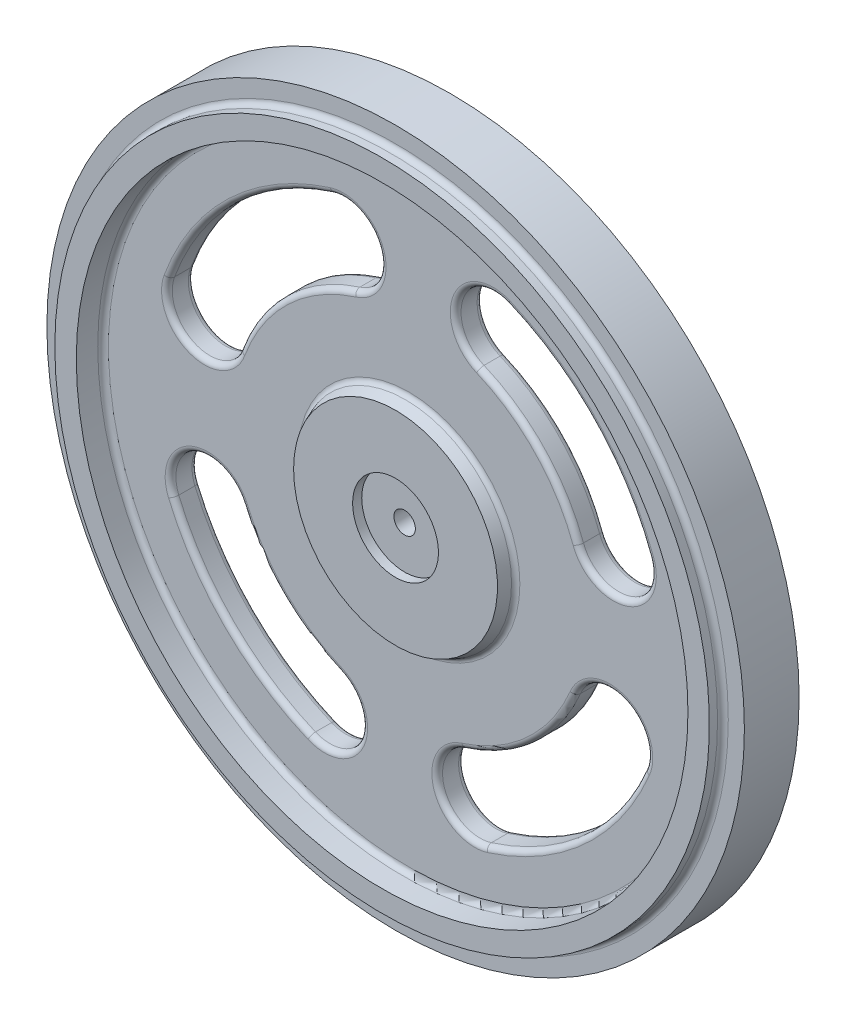
from build123d import *

# Parameters (mm, degrees)
EXTRUDE1_REACH = 7
FILLET1_R      = 0.5
EXTRUDE2_DEPTH = 3.85


with BuildPart() as part:
    # Sketch1 → Revolve1 (revolve)
    with BuildSketch(Plane(origin=(0, 0, 0), x_dir=(0, 0, -1), z_dir=(1, 0, 0)), mode=Mode.PRIVATE) as revolve1_sk:
        Polygon((-2.55, 32.5), (-2.55, 30.5), (-3.81, 30.5), (-3.81, 28.5), (-1.31, 28.5), (-1.31, 10), (-2.56, 9.5), (-2.56, 4), (-1.71, 4), (-1.71, 1), (-0.16, 1), (-0.16, 2.75), (3.69, 2.75), (3.69, 4.5), (1.19, 5), (1.19, 28.5), (3.69, 28.5), (3.69, 30.5), (2.55, 30.5), (2.55, 32.5), align=None)
    revolve(revolve1_sk.sketch.rotate(Axis((0, 0, -25), (0, 0, 1)), 90), axis=Axis((0, 0, -25), (0, 0, 1)))  # turned: the seam where the file's is

    # Sketch2 → Extrude1 (cut, up to next)
    with BuildSketch(Plane.XY.offset(1.31), mode=Mode.PRIVATE) as extrude1_sk1:
        with BuildLine():
            ThreePointArc((-5.074263955, 16.01536279), (-11.607764774, 12.144949442), (-15.769589482, 5.793103448))
            ThreePointArc((-15.769589482, 5.793103448), (-20.261817176, 3.714668858), (-22.340251766, 8.206896552))
            ThreePointArc((-22.340251766, 8.206896552), (-16.44433343, 17.205345043), (-7.188540604, 22.68843062))
            ThreePointArc((-7.188540604, 22.68843062), (-2.794868365, 20.409035029), (-5.074263955, 16.01536279))
        make_face()
    extrude1_tool1 = extrude(extrude1_sk1.sketch, amount=-EXTRUDE1_REACH, mode=Mode.PRIVATE) & part.part
    add(extrude1_tool1.solids().sort_by_distance((-13.327111, 13.943863, 1.31))[0], mode=Mode.SUBTRACT)
    # Sketch2 → Extrude1 (cut, up to next)
    with BuildSketch(Plane.XY.offset(1.31), mode=Mode.PRIVATE) as extrude1_sk2:
        with BuildLine():
            ThreePointArc((15.769589482, 5.793103448), (12.144949442, 11.607764774), (6.50009699, 15.491569937))
            ThreePointArc((6.50009699, 15.491569937), (4.626873459, 20.073167214), (9.208470736, 21.946390744))
            ThreePointArc((9.208470736, 21.946390744), (17.205345043, 16.44433343), (22.340251766, 8.206896552))
            ThreePointArc((22.340251766, 8.206896552), (20.261817176, 3.714668858), (15.769589482, 5.793103448))
        make_face()
    extrude1_tool2 = extrude(extrude1_sk2.sketch, amount=-EXTRUDE1_REACH, mode=Mode.PRIVATE) & part.part
    add(extrude1_tool2.solids().sort_by_distance((14.064816, 13.442714, 1.31))[0], mode=Mode.SUBTRACT)
    # Sketch2 → Extrude1 (cut, up to next)
    with BuildSketch(Plane.XY.offset(1.31), mode=Mode.PRIVATE) as extrude1_sk3:
        with BuildLine():
            ThreePointArc((5.074263955, -16.01536279), (11.330200869, -12.404295557), (15.491569937, -6.50009699))
            ThreePointArc((15.491569937, -6.50009699), (20.073167214, -4.626873459), (21.946390744, -9.208470736))
            ThreePointArc((21.946390744, -9.208470736), (16.051117898, -17.572752039), (7.188540604, -22.68843062))
            ThreePointArc((7.188540604, -22.68843062), (2.794868365, -20.409035029), (5.074263955, -16.01536279))
        make_face()
    extrude1_tool3 = extrude(extrude1_sk3.sketch, amount=-EXTRUDE1_REACH, mode=Mode.PRIVATE) & part.part
    add(extrude1_tool3.solids().sort_by_distance((13.06595, -14.304593, 1.31))[0], mode=Mode.SUBTRACT)
    # Sketch2 → Extrude1 (cut, up to next)
    with BuildSketch(Plane.XY.offset(1.31), mode=Mode.PRIVATE) as extrude1_sk4:
        with BuildLine():
            ThreePointArc((-15.491569937, -6.50009699), (-11.879393924, -11.879393924), (-6.50009699, -15.491569937))
            ThreePointArc((-6.50009699, -15.491569937), (-4.626873459, -20.073167214), (-9.208470736, -21.946390744))
            ThreePointArc((-9.208470736, -21.946390744), (-16.829141392, -16.829141392), (-21.946390744, -9.208470736))
            ThreePointArc((-21.946390744, -9.208470736), (-20.073167214, -4.626873459), (-15.491569937, -6.50009699))
        make_face()
    extrude1_tool4 = extrude(extrude1_sk4.sketch, amount=-EXTRUDE1_REACH, mode=Mode.PRIVATE) & part.part
    add(extrude1_tool4.solids().sort_by_distance((-13.812959, -13.812959, 1.31))[0], mode=Mode.SUBTRACT)

    # Fillet1
    fillet1_edges = [part.edges().sort_by_distance(p)[0] for p in [
        (10, 0, 1.31),
        (5, 0, -1.19),
        (28.5, 0, -1.19),
        (28.5, 0, -3.69),
        (30.5, 0, 2.55),
        (28.5, 0, 1.31),
        (-20.073167214, -4.626873459, -1.19),
        (-11.879393924, -11.879393924, -1.19),
        (-4.626873459, -20.073167214, -1.19),
        (-16.829141392, -16.829141392, -1.19),
        (-20.073167214, -4.626873459, 1.31),
        (-16.829141392, -16.829141392, 1.31),
        (-4.626873459, -20.073167214, 1.31),
        (-11.879393924, -11.879393924, 1.31),
        (2.794868365, -20.409035029, -1.19),
        (11.330200869, -12.404295557, -1.19),
        (20.073167214, -4.626873459, -1.19),
        (16.051117898, -17.572752039, -1.19),
        (2.794868365, -20.409035029, 1.31),
        (16.051117898, -17.572752039, 1.31),
        (20.073167214, -4.626873459, 1.31),
        (11.330200869, -12.404295557, 1.31),
        (-20.261817176, 3.714668858, -1.19),
        (-16.44433343, 17.205345043, -1.19),
        (-2.794868365, 20.409035029, -1.19),
        (-11.607764774, 12.144949442, -1.19),
        (-20.261817176, 3.714668858, 1.31),
        (-11.607764774, 12.144949442, 1.31),
        (-2.794868365, 20.409035029, 1.31),
        (-16.44433343, 17.205345043, 1.31),
        (20.261817176, 3.714668858, -1.19),
        (12.144949442, 11.607764774, -1.19),
        (4.626873459, 20.073167214, -1.19),
        (17.205345043, 16.44433343, -1.19),
        (20.261817176, 3.714668858, 1.31),
        (17.205345043, 16.44433343, 1.31),
        (4.626873459, 20.073167214, 1.31),
        (12.144949442, 11.607764774, 1.31),
    ]]
    fillet(fillet1_edges, radius=FILLET1_R)

    # Sketch3 → Extrude2 (cut)
    with BuildSketch(Plane(origin=(0, 0, -3.69), x_dir=(-1, 0, 0), z_dir=(0, 0, -1))):
        with BuildLine():
            Line((0.123745264, 2.76888782), (0.159844513, 2.973616835))
            ThreePointArc((0.159844513, 2.973616835), (0.168996766, 2.988915967), (0.186014831, 2.994227527))
            ThreePointArc((0.186014831, 2.994227527), (0.261467228, 2.988584094), (0.336753306, 2.981039619))
            ThreePointArc((0.336753306, 2.981039619), (0.352590485, 2.972853598), (0.358947029, 2.956197622))
            Line((0.358947029, 2.956197622), (0.358947029, 2.748310332))
            ThreePointArc((0.358947029, 2.748310332), (0.36508603, 2.731901105), (0.380488046, 2.723550779))
            ThreePointArc((0.380488046, 2.723550779), (0.429078731, 2.716319466), (0.477532489, 2.708221321))
            ThreePointArc((0.477532489, 2.708221321), (0.525833856, 2.699258927), (0.573967418, 2.689435146))
            ThreePointArc((0.573967418, 2.689435146), (0.591296559, 2.692014085), (0.60267762, 2.705334052))
            Line((0.60267762, 2.705334052), (0.67377926, 2.900684205))
            ThreePointArc((0.67377926, 2.900684205), (0.685449137, 2.914161637), (0.703131001, 2.916437346))
            ThreePointArc((0.703131001, 2.916437346), (0.776457135, 2.897777479), (0.849289364, 2.877274331))
            ThreePointArc((0.849289364, 2.877274331), (0.863464453, 2.866462577), (0.866832147, 2.84895584))
            Line((0.866832147, 2.84895584), (0.830732897, 2.644226825))
            ThreePointArc((0.830732897, 2.644226825), (0.833929201, 2.627000865), (0.847647208, 2.616102867))
            ThreePointArc((0.847647208, 2.616102867), (0.894243987, 2.60054373), (0.940555394, 2.584154707))
            ThreePointArc((0.940555394, 2.584154707), (0.986566652, 2.566941028), (1.032263076, 2.548908186))
            ThreePointArc((1.032263076, 2.548908186), (1.049776776, 2.548438772), (1.06329792, 2.559580079))
            Line((1.06329792, 2.559580079), (1.167241566, 2.739615754))
            ThreePointArc((1.167241566, 2.739615754), (1.181074482, 2.75086198), (1.198882892, 2.750032693))
            ThreePointArc((1.198882892, 2.750032693), (1.267854785, 2.718923361), (1.336020195, 2.686084518))
            ThreePointArc((1.336020195, 2.686084518), (1.348102491, 2.672975541), (1.348379009, 2.655149977))
            Line((1.348379009, 2.655149977), (1.277277368, 2.459799824))
            ThreePointArc((1.277277368, 2.459799824), (1.277433856, 2.442280533), (1.289051037, 2.429165993))
            ThreePointArc((1.289051037, 2.429165993), (1.332238091, 2.405751789), (1.375, 2.38156986))
            ThreePointArc((1.375, 2.38156986), (1.417323119, 2.356627925), (1.459193942, 2.330933942))
            ThreePointArc((1.459193942, 2.330933942), (1.476360057, 2.327430437), (1.491610452, 2.33605456))
            Line((1.491610452, 2.33605456), (1.625237827, 2.495305464))
            ThreePointArc((1.625237827, 2.495305464), (1.640813476, 2.503978774), (1.658207332, 2.500069688))
            ThreePointArc((1.658207332, 2.500069688), (1.720729309, 2.457456133), (1.782156728, 2.413279387))
            ThreePointArc((1.782156728, 2.413279387), (1.791779116, 2.398271495), (1.788956057, 2.380668725))
            Line((1.788956057, 2.380668725), (1.685012411, 2.20063305))
            ThreePointArc((1.685012411, 2.20063305), (1.682124329, 2.183352743), (1.691287704, 2.16842014))
            ThreePointArc((1.691287704, 2.16842014), (1.729752815, 2.137862297), (1.767665927, 2.106622219))
            ThreePointArc((1.767665927, 2.106622219), (1.805014941, 2.074709875), (1.841787938, 2.042135449))
            ThreePointArc((1.841787938, 2.042135449), (1.858084884, 2.035704305), (1.874601155, 2.041549205))
            Line((1.874601155, 2.041549205), (2.033852059, 2.17517658))
            ThreePointArc((2.033852059, 2.17517658), (2.050697184, 2.18101344), (2.067147982, 2.17414333))
            ThreePointArc((2.067147982, 2.17414333), (2.121320344, 2.121320344), (2.17414333, 2.067147982))
            ThreePointArc((2.17414333, 2.067147982), (2.18101344, 2.050697184), (2.17517658, 2.033852059))
            Line((2.17517658, 2.033852059), (2.041549205, 1.874601155))
            ThreePointArc((2.041549205, 1.874601155), (2.035704305, 1.858084884), (2.042135449, 1.841787938))
            ThreePointArc((2.042135449, 1.841787938), (2.074709875, 1.805014941), (2.106622219, 1.767665927))
            ThreePointArc((2.106622219, 1.767665927), (2.137862297, 1.729752815), (2.16842014, 1.691287704))
            ThreePointArc((2.16842014, 1.691287704), (2.183352743, 1.682124329), (2.20063305, 1.685012411))
            Line((2.20063305, 1.685012411), (2.380668725, 1.788956057))
            ThreePointArc((2.380668725, 1.788956057), (2.398271495, 1.791779116), (2.413279387, 1.782156728))
            ThreePointArc((2.413279387, 1.782156728), (2.457456133, 1.720729309), (2.500069688, 1.658207332))
            ThreePointArc((2.500069688, 1.658207332), (2.503978774, 1.640813476), (2.495305464, 1.625237827))
            Line((2.495305464, 1.625237827), (2.33605456, 1.491610452))
            ThreePointArc((2.33605456, 1.491610452), (2.327430437, 1.476360057), (2.330933942, 1.459193942))
            ThreePointArc((2.330933942, 1.459193942), (2.356627925, 1.417323119), (2.38156986, 1.375))
            ThreePointArc((2.38156986, 1.375), (2.405751789, 1.332238091), (2.429165993, 1.289051037))
            ThreePointArc((2.429165993, 1.289051037), (2.442280533, 1.277433856), (2.459799824, 1.277277368))
            Line((2.459799824, 1.277277368), (2.655149977, 1.348379009))
            ThreePointArc((2.655149977, 1.348379009), (2.672975541, 1.348102491), (2.686084518, 1.336020195))
            ThreePointArc((2.686084518, 1.336020195), (2.718923361, 1.267854785), (2.750032693, 1.198882892))
            ThreePointArc((2.750032693, 1.198882892), (2.75086198, 1.181074482), (2.739615754, 1.167241566))
            Line((2.739615754, 1.167241566), (2.559580079, 1.06329792))
            ThreePointArc((2.559580079, 1.06329792), (2.548438772, 1.049776776), (2.548908186, 1.032263076))
            ThreePointArc((2.548908186, 1.032263076), (2.566941028, 0.986566652), (2.584154707, 0.940555394))
            ThreePointArc((2.584154707, 0.940555394), (2.60054373, 0.894243987), (2.616102867, 0.847647208))
            ThreePointArc((2.616102867, 0.847647208), (2.627000865, 0.833929201), (2.644226825, 0.830732897))
            Line((2.644226825, 0.830732897), (2.84895584, 0.866832147))
            ThreePointArc((2.84895584, 0.866832147), (2.866462577, 0.863464453), (2.877274331, 0.849289364))
            ThreePointArc((2.877274331, 0.849289364), (2.897777479, 0.776457135), (2.916437346, 0.703131001))
            ThreePointArc((2.916437346, 0.703131001), (2.914161637, 0.685449137), (2.900684205, 0.67377926))
            Line((2.900684205, 0.67377926), (2.705334052, 0.60267762))
            ThreePointArc((2.705334052, 0.60267762), (2.692014085, 0.591296559), (2.689435146, 0.573967418))
            ThreePointArc((2.689435146, 0.573967418), (2.699258927, 0.525833856), (2.708221321, 0.477532489))
            ThreePointArc((2.708221321, 0.477532489), (2.716319466, 0.429078731), (2.723550779, 0.380488046))
            ThreePointArc((2.723550779, 0.380488046), (2.731901105, 0.36508603), (2.748310332, 0.358947029))
            Line((2.748310332, 0.358947029), (2.956197622, 0.358947029))
            ThreePointArc((2.956197622, 0.358947029), (2.972853598, 0.352590485), (2.981039619, 0.336753306))
            ThreePointArc((2.981039619, 0.336753306), (2.988584094, 0.261467228), (2.994227527, 0.186014831))
            ThreePointArc((2.994227527, 0.186014831), (2.988915967, 0.168996766), (2.973616835, 0.159844513))
            Line((2.973616835, 0.159844513), (2.76888782, 0.123745264))
            ThreePointArc((2.76888782, 0.123745264), (2.753793912, 0.114850096), (2.748244979, 0.098232052))
            ThreePointArc((2.748244979, 0.098232052), (2.74956121, 0.049123864), (2.75, 0))
            ThreePointArc((2.75, 0), (2.74956121, -0.049123864), (2.748244979, -0.098232052))
            ThreePointArc((2.748244979, -0.098232052), (2.753793912, -0.114850096), (2.76888782, -0.123745264))
            Line((2.76888782, -0.123745264), (2.973616835, -0.159844513))
            ThreePointArc((2.973616835, -0.159844513), (2.988915967, -0.168996766), (2.994227527, -0.186014831))
            ThreePointArc((2.994227527, -0.186014831), (2.988584094, -0.261467228), (2.981039619, -0.336753306))
            ThreePointArc((2.981039619, -0.336753306), (2.972853598, -0.352590485), (2.956197622, -0.358947029))
            Line((2.956197622, -0.358947029), (2.748310332, -0.358947029))
            ThreePointArc((2.748310332, -0.358947029), (2.731901105, -0.36508603), (2.723550779, -0.380488046))
            ThreePointArc((2.723550779, -0.380488046), (2.716319466, -0.429078731), (2.708221321, -0.477532489))
            ThreePointArc((2.708221321, -0.477532489), (2.699258927, -0.525833856), (2.689435146, -0.573967418))
            ThreePointArc((2.689435146, -0.573967418), (2.692014085, -0.591296559), (2.705334052, -0.60267762))
            Line((2.705334052, -0.60267762), (2.900684205, -0.67377926))
            ThreePointArc((2.900684205, -0.67377926), (2.914161637, -0.685449137), (2.916437346, -0.703131001))
            ThreePointArc((2.916437346, -0.703131001), (2.897777479, -0.776457135), (2.877274331, -0.849289364))
            ThreePointArc((2.877274331, -0.849289364), (2.866462577, -0.863464453), (2.84895584, -0.866832147))
            Line((2.84895584, -0.866832147), (2.644226825, -0.830732897))
            ThreePointArc((2.644226825, -0.830732897), (2.627000865, -0.833929201), (2.616102867, -0.847647208))
            ThreePointArc((2.616102867, -0.847647208), (2.60054373, -0.894243987), (2.584154707, -0.940555394))
            ThreePointArc((2.584154707, -0.940555394), (2.566941028, -0.986566652), (2.548908186, -1.032263076))
            ThreePointArc((2.548908186, -1.032263076), (2.548438772, -1.049776776), (2.559580079, -1.06329792))
            Line((2.559580079, -1.06329792), (2.739615754, -1.167241566))
            ThreePointArc((2.739615754, -1.167241566), (2.75086198, -1.181074482), (2.750032693, -1.198882892))
            ThreePointArc((2.750032693, -1.198882892), (2.718923361, -1.267854785), (2.686084518, -1.336020195))
            ThreePointArc((2.686084518, -1.336020195), (2.672975541, -1.348102491), (2.655149977, -1.348379009))
            Line((2.655149977, -1.348379009), (2.459799824, -1.277277368))
            ThreePointArc((2.459799824, -1.277277368), (2.442280533, -1.277433856), (2.429165993, -1.289051037))
            ThreePointArc((2.429165993, -1.289051037), (2.405751789, -1.332238091), (2.38156986, -1.375))
            ThreePointArc((2.38156986, -1.375), (2.356627925, -1.417323119), (2.330933942, -1.459193942))
            ThreePointArc((2.330933942, -1.459193942), (2.327430437, -1.476360057), (2.33605456, -1.491610452))
            Line((2.33605456, -1.491610452), (2.495305464, -1.625237827))
            ThreePointArc((2.495305464, -1.625237827), (2.503978774, -1.640813476), (2.500069688, -1.658207332))
            ThreePointArc((2.500069688, -1.658207332), (2.457456133, -1.720729309), (2.413279387, -1.782156728))
            ThreePointArc((2.413279387, -1.782156728), (2.398271495, -1.791779116), (2.380668725, -1.788956057))
            Line((2.380668725, -1.788956057), (2.20063305, -1.685012411))
            ThreePointArc((2.20063305, -1.685012411), (2.183352743, -1.682124329), (2.16842014, -1.691287704))
            ThreePointArc((2.16842014, -1.691287704), (2.137862297, -1.729752815), (2.106622219, -1.767665927))
            ThreePointArc((2.106622219, -1.767665927), (2.074709875, -1.805014941), (2.042135449, -1.841787938))
            ThreePointArc((2.042135449, -1.841787938), (2.035704305, -1.858084884), (2.041549205, -1.874601155))
            Line((2.041549205, -1.874601155), (2.17517658, -2.033852059))
            ThreePointArc((2.17517658, -2.033852059), (2.18101344, -2.050697184), (2.17414333, -2.067147982))
            ThreePointArc((2.17414333, -2.067147982), (2.121320344, -2.121320344), (2.067147982, -2.17414333))
            ThreePointArc((2.067147982, -2.17414333), (2.050697184, -2.18101344), (2.033852059, -2.17517658))
            Line((2.033852059, -2.17517658), (1.874601155, -2.041549205))
            ThreePointArc((1.874601155, -2.041549205), (1.858084884, -2.035704305), (1.841787938, -2.042135449))
            ThreePointArc((1.841787938, -2.042135449), (1.805014941, -2.074709875), (1.767665927, -2.106622219))
            ThreePointArc((1.767665927, -2.106622219), (1.729752815, -2.137862297), (1.691287704, -2.16842014))
            ThreePointArc((1.691287704, -2.16842014), (1.682124329, -2.183352743), (1.685012411, -2.20063305))
            Line((1.685012411, -2.20063305), (1.788956057, -2.380668725))
            ThreePointArc((1.788956057, -2.380668725), (1.791779116, -2.398271495), (1.782156728, -2.413279387))
            ThreePointArc((1.782156728, -2.413279387), (1.720729309, -2.457456133), (1.658207332, -2.500069688))
            ThreePointArc((1.658207332, -2.500069688), (1.640813476, -2.503978774), (1.625237827, -2.495305464))
            Line((1.625237827, -2.495305464), (1.491610452, -2.33605456))
            ThreePointArc((1.491610452, -2.33605456), (1.476360057, -2.327430437), (1.459193942, -2.330933942))
            ThreePointArc((1.459193942, -2.330933942), (1.417323119, -2.356627925), (1.375, -2.38156986))
            ThreePointArc((1.375, -2.38156986), (1.332238091, -2.405751789), (1.289051037, -2.429165993))
            ThreePointArc((1.289051037, -2.429165993), (1.277433856, -2.442280533), (1.277277368, -2.459799824))
            Line((1.277277368, -2.459799824), (1.348379009, -2.655149977))
            ThreePointArc((1.348379009, -2.655149977), (1.348102491, -2.672975541), (1.336020195, -2.686084518))
            ThreePointArc((1.336020195, -2.686084518), (1.267854785, -2.718923361), (1.198882892, -2.750032693))
            ThreePointArc((1.198882892, -2.750032693), (1.181074482, -2.75086198), (1.167241566, -2.739615754))
            Line((1.167241566, -2.739615754), (1.06329792, -2.559580079))
            ThreePointArc((1.06329792, -2.559580079), (1.049776776, -2.548438772), (1.032263076, -2.548908186))
            ThreePointArc((1.032263076, -2.548908186), (0.986566652, -2.566941028), (0.940555394, -2.584154707))
            ThreePointArc((0.940555394, -2.584154707), (0.894243987, -2.60054373), (0.847647208, -2.616102867))
            ThreePointArc((0.847647208, -2.616102867), (0.833929201, -2.627000865), (0.830732897, -2.644226825))
            Line((0.830732897, -2.644226825), (0.866832147, -2.84895584))
            ThreePointArc((0.866832147, -2.84895584), (0.863464453, -2.866462577), (0.849289364, -2.877274331))
            ThreePointArc((0.849289364, -2.877274331), (0.776457135, -2.897777479), (0.703131001, -2.916437346))
            ThreePointArc((0.703131001, -2.916437346), (0.685449137, -2.914161637), (0.67377926, -2.900684205))
            Line((0.67377926, -2.900684205), (0.60267762, -2.705334052))
            ThreePointArc((0.60267762, -2.705334052), (0.591296559, -2.692014085), (0.573967418, -2.689435146))
            ThreePointArc((0.573967418, -2.689435146), (0.525833856, -2.699258927), (0.477532489, -2.708221321))
            ThreePointArc((0.477532489, -2.708221321), (0.429078731, -2.716319466), (0.380488046, -2.723550779))
            ThreePointArc((0.380488046, -2.723550779), (0.36508603, -2.731901105), (0.358947029, -2.748310332))
            Line((0.358947029, -2.748310332), (0.358947029, -2.956197622))
            ThreePointArc((0.358947029, -2.956197622), (0.352590485, -2.972853598), (0.336753306, -2.981039619))
            ThreePointArc((0.336753306, -2.981039619), (0.261467228, -2.988584094), (0.186014831, -2.994227527))
            ThreePointArc((0.186014831, -2.994227527), (0.168996766, -2.988915967), (0.159844513, -2.973616835))
            Line((0.159844513, -2.973616835), (0.123745264, -2.76888782))
            ThreePointArc((0.123745264, -2.76888782), (0.114850096, -2.753793912), (0.098232052, -2.748244979))
            ThreePointArc((0.098232052, -2.748244979), (0.049123864, -2.74956121), (0, -2.75))
            ThreePointArc((0, -2.75), (-0.049123864, -2.74956121), (-0.098232052, -2.748244979))
            ThreePointArc((-0.098232052, -2.748244979), (-0.114850096, -2.753793912), (-0.123745264, -2.76888782))
            Line((-0.123745264, -2.76888782), (-0.159844513, -2.973616835))
            ThreePointArc((-0.159844513, -2.973616835), (-0.168996766, -2.988915967), (-0.186014831, -2.994227527))
            ThreePointArc((-0.186014831, -2.994227527), (-0.261467228, -2.988584094), (-0.336753306, -2.981039619))
            ThreePointArc((-0.336753306, -2.981039619), (-0.352590485, -2.972853598), (-0.358947029, -2.956197622))
            Line((-0.358947029, -2.956197622), (-0.358947029, -2.748310332))
            ThreePointArc((-0.358947029, -2.748310332), (-0.36508603, -2.731901105), (-0.380488046, -2.723550779))
            ThreePointArc((-0.380488046, -2.723550779), (-0.429078731, -2.716319466), (-0.477532489, -2.708221321))
            ThreePointArc((-0.477532489, -2.708221321), (-0.525833856, -2.699258927), (-0.573967418, -2.689435146))
            ThreePointArc((-0.573967418, -2.689435146), (-0.591296559, -2.692014085), (-0.60267762, -2.705334052))
            Line((-0.60267762, -2.705334052), (-0.67377926, -2.900684205))
            ThreePointArc((-0.67377926, -2.900684205), (-0.685449137, -2.914161637), (-0.703131001, -2.916437346))
            ThreePointArc((-0.703131001, -2.916437346), (-0.776457135, -2.897777479), (-0.849289364, -2.877274331))
            ThreePointArc((-0.849289364, -2.877274331), (-0.863464453, -2.866462577), (-0.866832147, -2.84895584))
            Line((-0.866832147, -2.84895584), (-0.830732897, -2.644226825))
            ThreePointArc((-0.830732897, -2.644226825), (-0.833929201, -2.627000865), (-0.847647208, -2.616102867))
            ThreePointArc((-0.847647208, -2.616102867), (-0.894243987, -2.60054373), (-0.940555394, -2.584154707))
            ThreePointArc((-0.940555394, -2.584154707), (-0.986566652, -2.566941028), (-1.032263076, -2.548908186))
            ThreePointArc((-1.032263076, -2.548908186), (-1.049776776, -2.548438772), (-1.06329792, -2.559580079))
            Line((-1.06329792, -2.559580079), (-1.167241566, -2.739615754))
            ThreePointArc((-1.167241566, -2.739615754), (-1.181074482, -2.75086198), (-1.198882892, -2.750032693))
            ThreePointArc((-1.198882892, -2.750032693), (-1.267854785, -2.718923361), (-1.336020195, -2.686084518))
            ThreePointArc((-1.336020195, -2.686084518), (-1.348102491, -2.672975541), (-1.348379009, -2.655149977))
            Line((-1.348379009, -2.655149977), (-1.277277368, -2.459799824))
            ThreePointArc((-1.277277368, -2.459799824), (-1.277433856, -2.442280533), (-1.289051037, -2.429165993))
            ThreePointArc((-1.289051037, -2.429165993), (-1.332238091, -2.405751789), (-1.375, -2.38156986))
            ThreePointArc((-1.375, -2.38156986), (-1.417323119, -2.356627925), (-1.459193942, -2.330933942))
            ThreePointArc((-1.459193942, -2.330933942), (-1.476360057, -2.327430437), (-1.491610452, -2.33605456))
            Line((-1.491610452, -2.33605456), (-1.625237827, -2.495305464))
            ThreePointArc((-1.625237827, -2.495305464), (-1.640813476, -2.503978774), (-1.658207332, -2.500069688))
            ThreePointArc((-1.658207332, -2.500069688), (-1.720729309, -2.457456133), (-1.782156728, -2.413279387))
            ThreePointArc((-1.782156728, -2.413279387), (-1.791779116, -2.398271495), (-1.788956057, -2.380668725))
            Line((-1.788956057, -2.380668725), (-1.685012411, -2.20063305))
            ThreePointArc((-1.685012411, -2.20063305), (-1.682124329, -2.183352743), (-1.691287704, -2.16842014))
            ThreePointArc((-1.691287704, -2.16842014), (-1.729752815, -2.137862297), (-1.767665927, -2.106622219))
            ThreePointArc((-1.767665927, -2.106622219), (-1.805014941, -2.074709875), (-1.841787938, -2.042135449))
            ThreePointArc((-1.841787938, -2.042135449), (-1.858084884, -2.035704305), (-1.874601155, -2.041549205))
            Line((-1.874601155, -2.041549205), (-2.033852059, -2.17517658))
            ThreePointArc((-2.033852059, -2.17517658), (-2.050697184, -2.18101344), (-2.067147982, -2.17414333))
            ThreePointArc((-2.067147982, -2.17414333), (-2.121320344, -2.121320344), (-2.17414333, -2.067147982))
            ThreePointArc((-2.17414333, -2.067147982), (-2.18101344, -2.050697184), (-2.17517658, -2.033852059))
            Line((-2.17517658, -2.033852059), (-2.041549205, -1.874601155))
            ThreePointArc((-2.041549205, -1.874601155), (-2.035704305, -1.858084884), (-2.042135449, -1.841787938))
            ThreePointArc((-2.042135449, -1.841787938), (-2.074709875, -1.805014941), (-2.106622219, -1.767665927))
            ThreePointArc((-2.106622219, -1.767665927), (-2.137862297, -1.729752815), (-2.16842014, -1.691287704))
            ThreePointArc((-2.16842014, -1.691287704), (-2.183352743, -1.682124329), (-2.20063305, -1.685012411))
            Line((-2.20063305, -1.685012411), (-2.380668725, -1.788956057))
            ThreePointArc((-2.380668725, -1.788956057), (-2.398271495, -1.791779116), (-2.413279387, -1.782156728))
            ThreePointArc((-2.413279387, -1.782156728), (-2.457456133, -1.720729309), (-2.500069688, -1.658207332))
            ThreePointArc((-2.500069688, -1.658207332), (-2.503978774, -1.640813476), (-2.495305464, -1.625237827))
            Line((-2.495305464, -1.625237827), (-2.33605456, -1.491610452))
            ThreePointArc((-2.33605456, -1.491610452), (-2.327430437, -1.476360057), (-2.330933942, -1.459193942))
            ThreePointArc((-2.330933942, -1.459193942), (-2.356627925, -1.417323119), (-2.38156986, -1.375))
            ThreePointArc((-2.38156986, -1.375), (-2.405751789, -1.332238091), (-2.429165993, -1.289051037))
            ThreePointArc((-2.429165993, -1.289051037), (-2.442280533, -1.277433856), (-2.459799824, -1.277277368))
            Line((-2.459799824, -1.277277368), (-2.655149977, -1.348379009))
            ThreePointArc((-2.655149977, -1.348379009), (-2.672975541, -1.348102491), (-2.686084518, -1.336020195))
            ThreePointArc((-2.686084518, -1.336020195), (-2.718923361, -1.267854785), (-2.750032693, -1.198882892))
            ThreePointArc((-2.750032693, -1.198882892), (-2.75086198, -1.181074482), (-2.739615754, -1.167241566))
            Line((-2.739615754, -1.167241566), (-2.559580079, -1.06329792))
            ThreePointArc((-2.559580079, -1.06329792), (-2.548438772, -1.049776776), (-2.548908186, -1.032263076))
            ThreePointArc((-2.548908186, -1.032263076), (-2.566941028, -0.986566652), (-2.584154707, -0.940555394))
            ThreePointArc((-2.584154707, -0.940555394), (-2.60054373, -0.894243987), (-2.616102867, -0.847647208))
            ThreePointArc((-2.616102867, -0.847647208), (-2.627000865, -0.833929201), (-2.644226825, -0.830732897))
            Line((-2.644226825, -0.830732897), (-2.84895584, -0.866832147))
            ThreePointArc((-2.84895584, -0.866832147), (-2.866462577, -0.863464453), (-2.877274331, -0.849289364))
            ThreePointArc((-2.877274331, -0.849289364), (-2.897777479, -0.776457135), (-2.916437346, -0.703131001))
            ThreePointArc((-2.916437346, -0.703131001), (-2.914161637, -0.685449137), (-2.900684205, -0.67377926))
            Line((-2.900684205, -0.67377926), (-2.705334052, -0.60267762))
            ThreePointArc((-2.705334052, -0.60267762), (-2.692014085, -0.591296559), (-2.689435146, -0.573967418))
            ThreePointArc((-2.689435146, -0.573967418), (-2.699258927, -0.525833856), (-2.708221321, -0.477532489))
            ThreePointArc((-2.708221321, -0.477532489), (-2.716319466, -0.429078731), (-2.723550779, -0.380488046))
            ThreePointArc((-2.723550779, -0.380488046), (-2.731901105, -0.36508603), (-2.748310332, -0.358947029))
            Line((-2.748310332, -0.358947029), (-2.956197622, -0.358947029))
            ThreePointArc((-2.956197622, -0.358947029), (-2.972853598, -0.352590485), (-2.981039619, -0.336753306))
            ThreePointArc((-2.981039619, -0.336753306), (-2.988584094, -0.261467228), (-2.994227527, -0.186014831))
            ThreePointArc((-2.994227527, -0.186014831), (-2.988915967, -0.168996766), (-2.973616835, -0.159844513))
            Line((-2.973616835, -0.159844513), (-2.76888782, -0.123745264))
            ThreePointArc((-2.76888782, -0.123745264), (-2.753793912, -0.114850096), (-2.748244979, -0.098232052))
            ThreePointArc((-2.748244979, -0.098232052), (-2.74956121, -0.049123864), (-2.75, 0))
            ThreePointArc((-2.75, 0), (-2.74956121, 0.049123864), (-2.748244979, 0.098232052))
            ThreePointArc((-2.748244979, 0.098232052), (-2.753793912, 0.114850096), (-2.76888782, 0.123745264))
            Line((-2.76888782, 0.123745264), (-2.973616835, 0.159844513))
            ThreePointArc((-2.973616835, 0.159844513), (-2.988915967, 0.168996766), (-2.994227527, 0.186014831))
            ThreePointArc((-2.994227527, 0.186014831), (-2.988584094, 0.261467228), (-2.981039619, 0.336753306))
            ThreePointArc((-2.981039619, 0.336753306), (-2.972853598, 0.352590485), (-2.956197622, 0.358947029))
            Line((-2.956197622, 0.358947029), (-2.748310332, 0.358947029))
            ThreePointArc((-2.748310332, 0.358947029), (-2.731901105, 0.36508603), (-2.723550779, 0.380488046))
            ThreePointArc((-2.723550779, 0.380488046), (-2.716319466, 0.429078731), (-2.708221321, 0.477532489))
            ThreePointArc((-2.708221321, 0.477532489), (-2.699258927, 0.525833856), (-2.689435146, 0.573967418))
            ThreePointArc((-2.689435146, 0.573967418), (-2.692014085, 0.591296559), (-2.705334052, 0.60267762))
            Line((-2.705334052, 0.60267762), (-2.900684205, 0.67377926))
            ThreePointArc((-2.900684205, 0.67377926), (-2.914161637, 0.685449137), (-2.916437346, 0.703131001))
            ThreePointArc((-2.916437346, 0.703131001), (-2.897777479, 0.776457135), (-2.877274331, 0.849289364))
            ThreePointArc((-2.877274331, 0.849289364), (-2.866462577, 0.863464453), (-2.84895584, 0.866832147))
            Line((-2.84895584, 0.866832147), (-2.644226825, 0.830732897))
            ThreePointArc((-2.644226825, 0.830732897), (-2.627000865, 0.833929201), (-2.616102867, 0.847647208))
            ThreePointArc((-2.616102867, 0.847647208), (-2.60054373, 0.894243987), (-2.584154707, 0.940555394))
            ThreePointArc((-2.584154707, 0.940555394), (-2.566941028, 0.986566652), (-2.548908186, 1.032263076))
            ThreePointArc((-2.548908186, 1.032263076), (-2.548438772, 1.049776776), (-2.559580079, 1.06329792))
            Line((-2.559580079, 1.06329792), (-2.739615754, 1.167241566))
            ThreePointArc((-2.739615754, 1.167241566), (-2.75086198, 1.181074482), (-2.750032693, 1.198882892))
            ThreePointArc((-2.750032693, 1.198882892), (-2.718923361, 1.267854785), (-2.686084518, 1.336020195))
            ThreePointArc((-2.686084518, 1.336020195), (-2.672975541, 1.348102491), (-2.655149977, 1.348379009))
            Line((-2.655149977, 1.348379009), (-2.459799824, 1.277277368))
            ThreePointArc((-2.459799824, 1.277277368), (-2.442280533, 1.277433856), (-2.429165993, 1.289051037))
            ThreePointArc((-2.429165993, 1.289051037), (-2.405751789, 1.332238091), (-2.38156986, 1.375))
            ThreePointArc((-2.38156986, 1.375), (-2.356627925, 1.417323119), (-2.330933942, 1.459193942))
            ThreePointArc((-2.330933942, 1.459193942), (-2.327430437, 1.476360057), (-2.33605456, 1.491610452))
            Line((-2.33605456, 1.491610452), (-2.495305464, 1.625237827))
            ThreePointArc((-2.495305464, 1.625237827), (-2.503978774, 1.640813476), (-2.500069688, 1.658207332))
            ThreePointArc((-2.500069688, 1.658207332), (-2.457456133, 1.720729309), (-2.413279387, 1.782156728))
            ThreePointArc((-2.413279387, 1.782156728), (-2.398271495, 1.791779116), (-2.380668725, 1.788956057))
            Line((-2.380668725, 1.788956057), (-2.20063305, 1.685012411))
            ThreePointArc((-2.20063305, 1.685012411), (-2.183352743, 1.682124329), (-2.16842014, 1.691287704))
            ThreePointArc((-2.16842014, 1.691287704), (-2.137862297, 1.729752815), (-2.106622219, 1.767665927))
            ThreePointArc((-2.106622219, 1.767665927), (-2.074709875, 1.805014941), (-2.042135449, 1.841787938))
            ThreePointArc((-2.042135449, 1.841787938), (-2.035704305, 1.858084884), (-2.041549205, 1.874601155))
            Line((-2.041549205, 1.874601155), (-2.17517658, 2.033852059))
            ThreePointArc((-2.17517658, 2.033852059), (-2.18101344, 2.050697184), (-2.17414333, 2.067147982))
            ThreePointArc((-2.17414333, 2.067147982), (-2.121320344, 2.121320344), (-2.067147982, 2.17414333))
            ThreePointArc((-2.067147982, 2.17414333), (-2.050697184, 2.18101344), (-2.033852059, 2.17517658))
            Line((-2.033852059, 2.17517658), (-1.874601155, 2.041549205))
            ThreePointArc((-1.874601155, 2.041549205), (-1.858084884, 2.035704305), (-1.841787938, 2.042135449))
            ThreePointArc((-1.841787938, 2.042135449), (-1.805014941, 2.074709875), (-1.767665927, 2.106622219))
            ThreePointArc((-1.767665927, 2.106622219), (-1.729752815, 2.137862297), (-1.691287704, 2.16842014))
            ThreePointArc((-1.691287704, 2.16842014), (-1.682124329, 2.183352743), (-1.685012411, 2.20063305))
            Line((-1.685012411, 2.20063305), (-1.788956057, 2.380668725))
            ThreePointArc((-1.788956057, 2.380668725), (-1.791779116, 2.398271495), (-1.782156728, 2.413279387))
            ThreePointArc((-1.782156728, 2.413279387), (-1.720729309, 2.457456133), (-1.658207332, 2.500069688))
            ThreePointArc((-1.658207332, 2.500069688), (-1.640813476, 2.503978774), (-1.625237827, 2.495305464))
            Line((-1.625237827, 2.495305464), (-1.491610452, 2.33605456))
            ThreePointArc((-1.491610452, 2.33605456), (-1.476360057, 2.327430437), (-1.459193942, 2.330933942))
            ThreePointArc((-1.459193942, 2.330933942), (-1.417323119, 2.356627925), (-1.375, 2.38156986))
            ThreePointArc((-1.375, 2.38156986), (-1.332238091, 2.405751789), (-1.289051037, 2.429165993))
            ThreePointArc((-1.289051037, 2.429165993), (-1.277433856, 2.442280533), (-1.277277368, 2.459799824))
            Line((-1.277277368, 2.459799824), (-1.348379009, 2.655149977))
            ThreePointArc((-1.348379009, 2.655149977), (-1.348102491, 2.672975541), (-1.336020195, 2.686084518))
            ThreePointArc((-1.336020195, 2.686084518), (-1.267854785, 2.718923361), (-1.198882892, 2.750032693))
            ThreePointArc((-1.198882892, 2.750032693), (-1.181074482, 2.75086198), (-1.167241566, 2.739615754))
            Line((-1.167241566, 2.739615754), (-1.06329792, 2.559580079))
            ThreePointArc((-1.06329792, 2.559580079), (-1.049776776, 2.548438772), (-1.032263076, 2.548908186))
            ThreePointArc((-1.032263076, 2.548908186), (-0.986566652, 2.566941028), (-0.940555394, 2.584154707))
            ThreePointArc((-0.940555394, 2.584154707), (-0.894243987, 2.60054373), (-0.847647208, 2.616102867))
            ThreePointArc((-0.847647208, 2.616102867), (-0.833929201, 2.627000865), (-0.830732897, 2.644226825))
            Line((-0.830732897, 2.644226825), (-0.866832147, 2.84895584))
            ThreePointArc((-0.866832147, 2.84895584), (-0.863464453, 2.866462577), (-0.849289364, 2.877274331))
            ThreePointArc((-0.849289364, 2.877274331), (-0.776457135, 2.897777479), (-0.703131001, 2.916437346))
            ThreePointArc((-0.703131001, 2.916437346), (-0.685449137, 2.914161637), (-0.67377926, 2.900684205))
            Line((-0.67377926, 2.900684205), (-0.60267762, 2.705334052))
            ThreePointArc((-0.60267762, 2.705334052), (-0.591296559, 2.692014085), (-0.573967418, 2.689435146))
            ThreePointArc((-0.573967418, 2.689435146), (-0.525833856, 2.699258927), (-0.477532489, 2.708221321))
            ThreePointArc((-0.477532489, 2.708221321), (-0.429078731, 2.716319466), (-0.380488046, 2.723550779))
            ThreePointArc((-0.380488046, 2.723550779), (-0.36508603, 2.731901105), (-0.358947029, 2.748310332))
            Line((-0.358947029, 2.748310332), (-0.358947029, 2.956197622))
            ThreePointArc((-0.358947029, 2.956197622), (-0.352590485, 2.972853598), (-0.336753306, 2.981039619))
            ThreePointArc((-0.336753306, 2.981039619), (-0.261467228, 2.988584094), (-0.186014831, 2.994227527))
            ThreePointArc((-0.186014831, 2.994227527), (-0.168996766, 2.988915967), (-0.159844513, 2.973616835))
            Line((-0.159844513, 2.973616835), (-0.123745264, 2.76888782))
            ThreePointArc((-0.123745264, 2.76888782), (-0.114850096, 2.753793912), (-0.098232052, 2.748244979))
            ThreePointArc((-0.098232052, 2.748244979), (-0.049123864, 2.74956121), (0, 2.75))
            ThreePointArc((0, 2.75), (0.049123864, 2.74956121), (0.098232052, 2.748244979))
            ThreePointArc((0.098232052, 2.748244979), (0.114850096, 2.753793912), (0.123745264, 2.76888782))
        make_face()
    extrude(amount=-EXTRUDE2_DEPTH, mode=Mode.SUBTRACT)


solid = part.part
